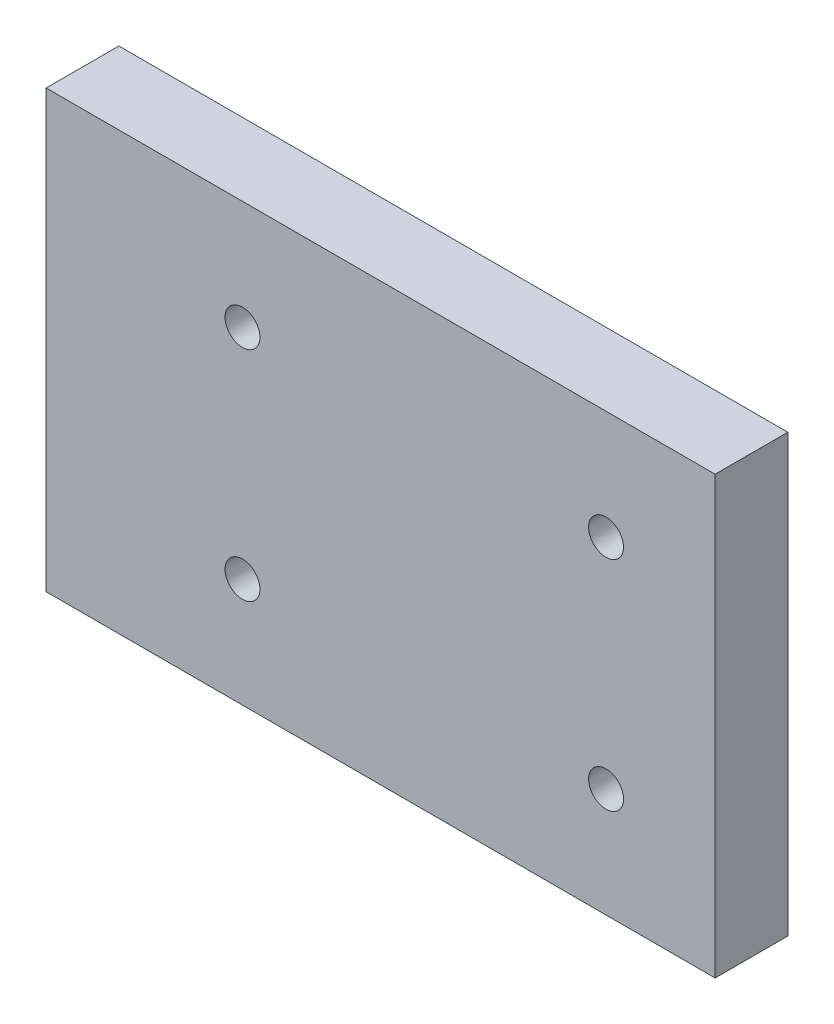
from build123d import *

# Parameters (mm, degrees)
SKETCH1_W           = 58.42
SKETCH1_H           = 38.1
SKETCH1_R           = 1.524
BOSS_EXTRUDE1_DEPTH = 6.35


with BuildPart() as part:
    # Sketch1 → Boss-Extrude1 (new body)
    with BuildSketch(Plane.XY):
        with Locations((2.54, 37.916126629)):
            Rectangle(SKETCH1_W, SKETCH1_H)
        with Locations((22.225, 47.441126629)):
            Circle(SKETCH1_R, mode=Mode.SUBTRACT)
        with Locations((22.225, 28.391126629)):
            Circle(SKETCH1_R, mode=Mode.SUBTRACT)
        with Locations((-9.525, 47.441126629)):
            Circle(SKETCH1_R, mode=Mode.SUBTRACT)
        with Locations((-9.525, 28.391126629)):
            Circle(SKETCH1_R, mode=Mode.SUBTRACT)
    extrude(amount=BOSS_EXTRUDE1_DEPTH)


solid = part.part
